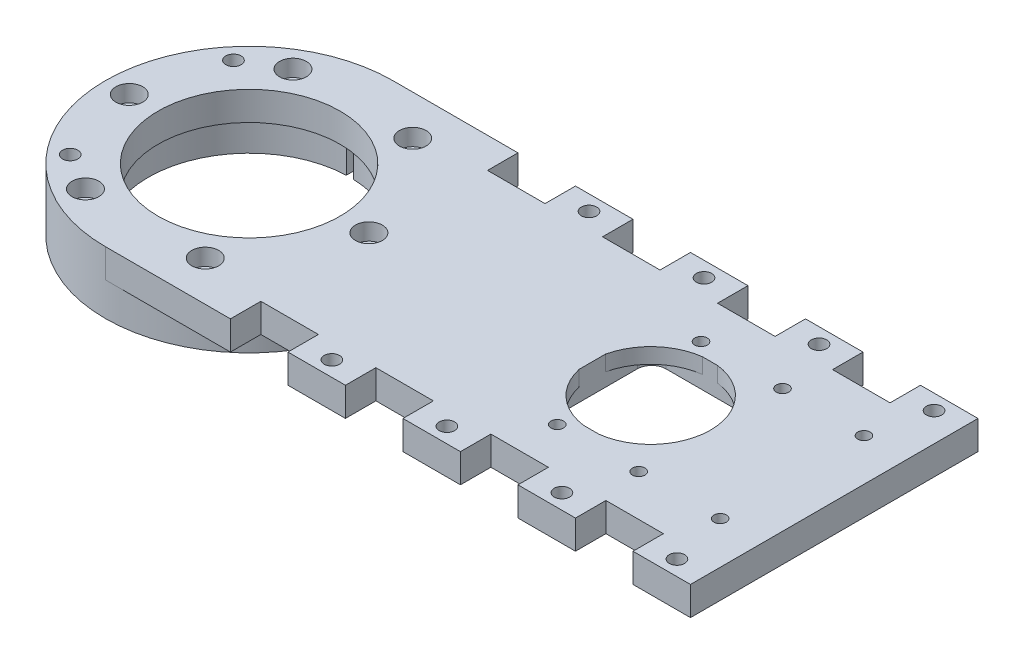
from build123d import *

# Parameters (mm, degrees)
SKETCH1_R           = 1.3
BOSS_EXTRUDE1_DEPTH = 2.8
SKETCH2_W           = 55.6
SKETCH2_H           = 35.6
SKETCH2_R           = 1.3
BOSS_EXTRUDE2_DEPTH = 3.2
FILLET1_R           = 3
SKETCH4_R           = 19
BOSS_EXTRUDE3_DEPTH = 6
BOSS_EXTRUDE4_DEPTH = 7
SKETCH6_R           = 1.6
CUT_EXTRUDE2_DEPTH  = 14
SKETCH8_R           = 2.8
CUT_EXTRUDE3_DEPTH  = 3.5
BOSS_EXTRUDE5_DEPTH = 6
CUT_EXTRUDE4_REACH  = 8
SKETCH10_W          = 12
SKETCH10_H          = 6.35
SKETCH11_R          = 1.6
CUT_EXTRUDE5_DEPTH  = 10
SKETCH13_R          = 1.6
CUT_EXTRUDE6_DEPTH  = 14
SKETCH14_R          = 2.8
CUT_EXTRUDE7_DEPTH  = 7


with BuildPart() as part:
    # Sketch1 → Boss-Extrude1 (new body)
    with BuildSketch(Plane(origin=(0, 0, 0), x_dir=(1, 0, 0), z_dir=(0, 1, 0))):
        Polygon((-4.5, 17.8), (38.3, 17.8), (38.3, -17.8), (-4.5, -17.8), (-12.2, -17.8), (-17.3, -17.8), (-17.3, 17.8), (-12.2, 17.8), align=None)
        with Locations((-4.5, 15)):
            Circle(SKETCH1_R, mode=Mode.SUBTRACT)
        with Locations((12.5, 15)):
            Circle(SKETCH1_R, mode=Mode.SUBTRACT)
        with Locations((29.5, 15)):
            Circle(SKETCH1_R, mode=Mode.SUBTRACT)
        with Locations((29.5, -15)):
            Circle(SKETCH1_R, mode=Mode.SUBTRACT)
        with Locations((12.5, -15)):
            Circle(SKETCH1_R, mode=Mode.SUBTRACT)
        with Locations((-4.5, -15)):
            Circle(SKETCH1_R, mode=Mode.SUBTRACT)
        Polygon((-4.5, 12.4), (33.2, 12.4), (33.2, -12.4), (-4.5, -12.4), (-12.2, -12.4), (-12.2, 12.4), align=None, mode=Mode.SUBTRACT)
    extrude(amount=BOSS_EXTRUDE1_DEPTH)

    # Sketch2 → Boss-Extrude2 (add)
    with BuildSketch(Plane(origin=(0, 2.8, 0), x_dir=(1, 0, 0), z_dir=(0, 1, 0))):
        with Locations((10.5, 0)):
            Rectangle(SKETCH2_W, SKETCH2_H)
        with Locations((-4.5, -15)):
            Circle(SKETCH2_R, mode=Mode.SUBTRACT)
        with Locations((12.5, -15)):
            Circle(SKETCH2_R, mode=Mode.SUBTRACT)
        with Locations((29.5, -15)):
            Circle(SKETCH2_R, mode=Mode.SUBTRACT)
        with Locations((29.5, 15)):
            Circle(SKETCH2_R, mode=Mode.SUBTRACT)
        with Locations((12.5, 15)):
            Circle(SKETCH2_R, mode=Mode.SUBTRACT)
        with Locations((-4.5, 15)):
            Circle(SKETCH2_R, mode=Mode.SUBTRACT)
        with BuildLine():
            Line((-12.2, 2.722131518), (-12.2, -2.722131518))
            ThreePointArc((-12.2, -2.722131518), (-8.418635414, -9.239944684), (-1.577973384, -12.4))
            Line((-1.577973384, -12.4), (1.577973384, -12.4))
            ThreePointArc((1.577973384, -12.4), (12.5, 0), (1.577973384, 12.4))
            Line((1.577973384, 12.4), (-1.577973384, 12.4))
            ThreePointArc((-1.577973384, 12.4), (-8.418635414, 9.239944684), (-12.2, 2.722131518))
        make_face(mode=Mode.SUBTRACT)
    extrude(amount=BOSS_EXTRUDE2_DEPTH)

    # Fillet1
    fillet1_edges = [part.edges().sort_by_distance(p)[0] for p in [
        (-12.2, 1.4, -12.4),
        (-12.2, 1.4, 12.4),
        (33.2, 1.4, 12.4),
        (33.2, 1.4, -12.4),
    ]]
    fillet(fillet1_edges, radius=FILLET1_R)

    # Sketch4 → Boss-Extrude3 (add)
    with BuildSketch(Plane(origin=(0, 6, 0), x_dir=(1, 0, 0), z_dir=(0, 1, 0))):
        with BuildLine():
            ThreePointArc((-59.656294031, -17.8), (-113.805, 0), (-59.656294031, 17.8))
            Line((-59.656294031, 17.8), (-17.3, 17.8))
            Line((-17.3, 17.8), (-17.3, -17.8))
            Line((-17.3, -17.8), (-59.656294031, -17.8))
        make_face()
        with Locations((-83.805, 0)):
            Circle(SKETCH4_R, mode=Mode.SUBTRACT)
    extrude(amount=-BOSS_EXTRUDE3_DEPTH)

    # Sketch5 → Boss-Extrude4 (add)
    with BuildSketch(Plane.XZ):
        with BuildLine():
            ThreePointArc((-59.656294031, -17.8), (-53.805, 0), (-59.656294031, 17.8))
            ThreePointArc((-59.656294031, 17.8), (-113.805, 0), (-59.656294031, -17.8))
        make_face()
        with BuildLine():
            ThreePointArc((-84.555, 21.036634712), (-104.855, 0), (-84.555, -21.036634712))
            Line((-84.555, -21.036634712), (-84.555, -26.036634712))
            Line((-84.555, -26.036634712), (-83.055, -26.036634712))
            Line((-83.055, -26.036634712), (-83.055, -21.036634712))
            ThreePointArc((-83.055, -21.036634712), (-62.755, 0), (-83.055, 21.036634712))
            Line((-83.055, 21.036634712), (-83.055, 26.036634712))
            Line((-83.055, 26.036634712), (-84.555, 26.036634712))
            Line((-84.555, 26.036634712), (-84.555, 21.036634712))
        make_face(mode=Mode.SUBTRACT)
    extrude(amount=BOSS_EXTRUDE4_DEPTH)

    # Sketch6 → Cut-Extrude2 (cut, through all)
    with BuildSketch(Plane.XZ.offset(7)):
        with Locations((-58.805, 0)):
            Circle(SKETCH6_R)
        with Locations((-71.305, -21.650635095)):
            Circle(SKETCH6_R)
        with Locations((-96.305, -21.650635095)):
            Circle(SKETCH6_R)
        with Locations((-108.805, 0)):
            Circle(SKETCH6_R)
        with Locations((-96.305, 21.650635095)):
            Circle(SKETCH6_R)
        with Locations((-71.305, 21.650635095)):
            Circle(SKETCH6_R)
    extrude(amount=-CUT_EXTRUDE2_DEPTH, mode=Mode.SUBTRACT)

    # Sketch8 → Cut-Extrude3 (cut)
    with BuildSketch(Plane(origin=(0, 6, 0), x_dir=(1, 0, 0), z_dir=(0, 1, 0))):
        with Locations((-96.305, 21.650635095)):
            Circle(SKETCH8_R)
        with Locations((-71.305, 21.650635095)):
            Circle(SKETCH8_R)
        with Locations((-58.805, 0)):
            Circle(SKETCH8_R)
        with Locations((-71.305, -21.650635095)):
            Circle(SKETCH8_R)
        with Locations((-96.305, -21.650635095)):
            Circle(SKETCH8_R)
        with Locations((-108.805, 0)):
            Circle(SKETCH8_R)
    extrude(amount=-CUT_EXTRUDE3_DEPTH, mode=Mode.SUBTRACT)

    # Sketch9 → Boss-Extrude5 (add)
    with BuildSketch(Plane(origin=(0, 6, 0), x_dir=(1, 0, 0), z_dir=(0, 1, 0))):
        with BuildLine():
            Line((-59.656294031, 17.8), (38.3, 17.8))
            Line((38.3, 17.8), (38.3, 30))
            Line((38.3, 30), (-83.805, 30))
            ThreePointArc((-83.805, 30), (-70.277250742, 26.776855678), (-59.656294031, 17.8))
        make_face()
    boss_extrude5 = extrude(amount=-BOSS_EXTRUDE5_DEPTH)

    # Mirror1: Boss-Extrude5 across plane
    add(boss_extrude5.mirror(Plane.XY))

    # Sketch10 → Cut-Extrude4 (cut, up to next)
    with BuildSketch(Plane.XZ, mode=Mode.PRIVATE) as cut_extrude4_sk1:
        with Locations((20.3, -26.825)):
            Rectangle(SKETCH10_W, SKETCH10_H)
    cut_extrude4_tool1 = extrude(cut_extrude4_sk1.sketch, amount=-CUT_EXTRUDE4_REACH, mode=Mode.PRIVATE) & part.part
    add(cut_extrude4_tool1.solids().sort_by_distance((20.3, 0, -26.825))[0], mode=Mode.SUBTRACT)
    # Sketch10 → Cut-Extrude4 (cut, up to next)
    with BuildSketch(Plane.XZ, mode=Mode.PRIVATE) as cut_extrude4_sk2:
        with Locations((-3.7, -26.825)):
            Rectangle(SKETCH10_W, SKETCH10_H)
    cut_extrude4_tool2 = extrude(cut_extrude4_sk2.sketch, amount=-CUT_EXTRUDE4_REACH, mode=Mode.PRIVATE) & part.part
    add(cut_extrude4_tool2.solids().sort_by_distance((-3.7, 0, -26.825))[0], mode=Mode.SUBTRACT)
    # Sketch10 → Cut-Extrude4 (cut, up to next)
    with BuildSketch(Plane.XZ, mode=Mode.PRIVATE) as cut_extrude4_sk3:
        with Locations((-27.7, -26.825)):
            Rectangle(SKETCH10_W, SKETCH10_H)
    cut_extrude4_tool3 = extrude(cut_extrude4_sk3.sketch, amount=-CUT_EXTRUDE4_REACH, mode=Mode.PRIVATE) & part.part
    add(cut_extrude4_tool3.solids().sort_by_distance((-27.7, 0, -26.825))[0], mode=Mode.SUBTRACT)
    # Sketch10 → Cut-Extrude4 (cut, up to next)
    with BuildSketch(Plane.XZ, mode=Mode.PRIVATE) as cut_extrude4_sk4:
        with Locations((-51.7, -26.825)):
            Rectangle(SKETCH10_W, SKETCH10_H)
    cut_extrude4_tool4 = extrude(cut_extrude4_sk4.sketch, amount=-CUT_EXTRUDE4_REACH, mode=Mode.PRIVATE) & part.part
    add(cut_extrude4_tool4.solids().sort_by_distance((-51.7, 0, -26.825))[0], mode=Mode.SUBTRACT)
    # Sketch10 → Cut-Extrude4 (cut, up to next)
    with BuildSketch(Plane.XZ, mode=Mode.PRIVATE) as cut_extrude4_sk5:
        with Locations((20.3, 26.825)):
            Rectangle(SKETCH10_W, SKETCH10_H)
    cut_extrude4_tool5 = extrude(cut_extrude4_sk5.sketch, amount=-CUT_EXTRUDE4_REACH, mode=Mode.PRIVATE) & part.part
    add(cut_extrude4_tool5.solids().sort_by_distance((20.3, 0, 26.825))[0], mode=Mode.SUBTRACT)
    # Sketch10 → Cut-Extrude4 (cut, up to next)
    with BuildSketch(Plane.XZ, mode=Mode.PRIVATE) as cut_extrude4_sk6:
        with Locations((-3.7, 26.825)):
            Rectangle(SKETCH10_W, SKETCH10_H)
    cut_extrude4_tool6 = extrude(cut_extrude4_sk6.sketch, amount=-CUT_EXTRUDE4_REACH, mode=Mode.PRIVATE) & part.part
    add(cut_extrude4_tool6.solids().sort_by_distance((-3.7, 0, 26.825))[0], mode=Mode.SUBTRACT)
    # Sketch10 → Cut-Extrude4 (cut, up to next)
    with BuildSketch(Plane.XZ, mode=Mode.PRIVATE) as cut_extrude4_sk7:
        with Locations((-27.7, 26.825)):
            Rectangle(SKETCH10_W, SKETCH10_H)
    cut_extrude4_tool7 = extrude(cut_extrude4_sk7.sketch, amount=-CUT_EXTRUDE4_REACH, mode=Mode.PRIVATE) & part.part
    add(cut_extrude4_tool7.solids().sort_by_distance((-27.7, 0, 26.825))[0], mode=Mode.SUBTRACT)
    # Sketch10 → Cut-Extrude4 (cut, up to next)
    with BuildSketch(Plane.XZ, mode=Mode.PRIVATE) as cut_extrude4_sk8:
        with Locations((-51.7, 26.825)):
            Rectangle(SKETCH10_W, SKETCH10_H)
    cut_extrude4_tool8 = extrude(cut_extrude4_sk8.sketch, amount=-CUT_EXTRUDE4_REACH, mode=Mode.PRIVATE) & part.part
    add(cut_extrude4_tool8.solids().sort_by_distance((-51.7, 0, 26.825))[0], mode=Mode.SUBTRACT)

    # Sketch11 → Cut-Extrude5 (cut)
    with BuildSketch(Plane.XZ):
        with Locations((-39.7, -26.825)):
            Circle(SKETCH11_R)
        with Locations((-15.7, -26.825)):
            Circle(SKETCH11_R)
        with Locations((8.3, -26.825)):
            Circle(SKETCH11_R)
        with Locations((32.3, -26.825)):
            Circle(SKETCH11_R)
        with Locations((32.3, 26.825)):
            Circle(SKETCH11_R)
        with Locations((8.3, 26.825)):
            Circle(SKETCH11_R)
        with Locations((-15.7, 26.825)):
            Circle(SKETCH11_R)
        with Locations((-39.7, 26.825)):
            Circle(SKETCH11_R)
    extrude(amount=-CUT_EXTRUDE5_DEPTH, mode=Mode.SUBTRACT)

    # Sketch13 → Cut-Extrude6 (cut, through all)
    with BuildSketch(Plane(origin=(0, 6, 0), x_dir=(1, 0, 0), z_dir=(0, 1, 0))):
        with Locations((-104.105177743, -17.033871657)):
            Circle(SKETCH13_R)
        with Locations((-104.105177743, 17.033871657)):
            Circle(SKETCH13_R)
    extrude(amount=-CUT_EXTRUDE6_DEPTH, mode=Mode.SUBTRACT)

    # Sketch14 → Cut-Extrude7 (cut)
    with BuildSketch(Plane.XZ.offset(7)):
        with Locations((-104.105177743, 17.033871657)):
            Circle(SKETCH14_R)
        with Locations((-104.105177743, -17.033871657)):
            Circle(SKETCH14_R)
    extrude(amount=-CUT_EXTRUDE7_DEPTH, mode=Mode.SUBTRACT)


solid = part.part
